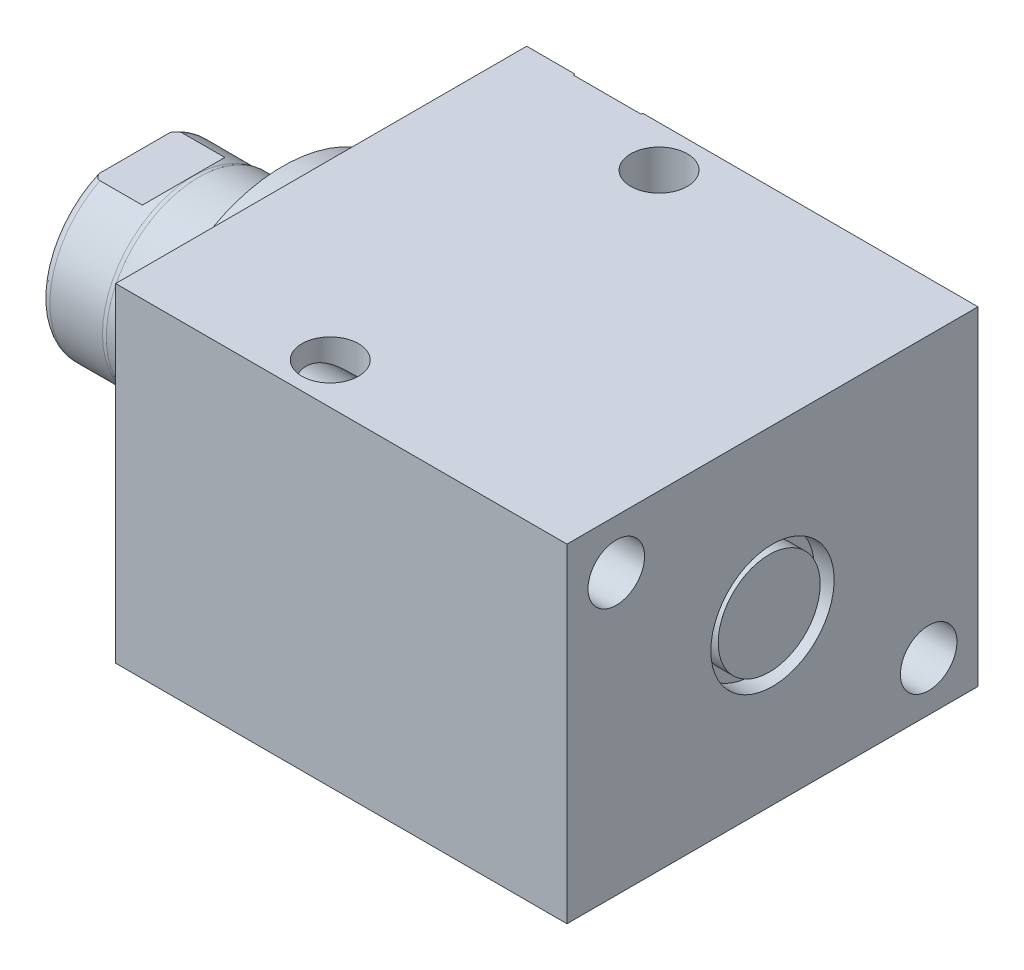
from build123d import *

# Parameters (mm, degrees)
SKETCH1_W          = 63.5
SKETCH1_H          = 50.8
EXTRUDE1_DEPTH     = 69.723
SKETCH5_R          = 22.225
EXTRUDE2_DEPTH     = 5.969
SKETCH6_W          = 14.2875
SKETCH6_H          = 22.86
CUT_EXTRUDE4_DEPTH = 30.48
SKETCH13_R         = 7.874
EXTRUDE3_DEPTH     = 2.54
HOLE1_D            = 8.7376
HOLE1_DEPTH        = 69.723
HOLE2_D            = 8.7376
HOLE2_DEPTH        = 50.8
SKETCH18_R         = 7.874
EXTRUDE4_DEPTH     = 2.54


with BuildPart() as part:
    # Sketch1 → Extrude1 (new body)
    with BuildSketch(Plane(origin=(0, 0, 0), x_dir=(0, 0, -1), z_dir=(1, 0, 0))):
        Rectangle(SKETCH1_W, SKETCH1_H)
    extrude(amount=EXTRUDE1_DEPTH)

    # S2D0002 → Cut-Revolve1 (revolve, cut)
    with BuildSketch(Plane(origin=(0, 17.4498, 0), x_dir=(-1, 0, 0), z_dir=(0, 1, 0)), mode=Mode.PRIVATE) as cut_revolve1_sk:
        Polygon((-18.8849, -31.496), (-22.225, -31.496), (-22.225, -31.75), (-12.7, -31.75), (-12.7, -17.526), (-17.6784, -17.526), (-17.6784, -28.279393135), (-18.342306865, -28.9433), align=None)
    revolve(cut_revolve1_sk.sketch.rotate(Axis((12.7, 17.4498, -19.13842003), (0, 0, 1)), 180), axis=Axis((12.7, 17.4498, -19.13842003), (0, 0, 1)), mode=Mode.SUBTRACT)  # turned: the seam where the file's is

    # Sketch3 → Cut-Revolve2 (revolve, cut)
    with BuildSketch(Plane(origin=(41.148, 0, -25.146), x_dir=(1, 0, 0), z_dir=(0, 1, 0))):
        Polygon((18.8849, 6.35), (22.225, 6.35), (22.225, 6.604), (12.7, 6.604), (12.7, -7.62), (17.6784, -7.62), (17.6784, 3.133393135), (18.342306865, 3.7973), align=None)
    revolve(axis=Axis((53.848, 0, -3.189624441), (0, 0, -1)), mode=Mode.SUBTRACT)

    # Sketch4 → Cut-Revolve3 (revolve, cut)
    with BuildSketch(Plane(origin=(53.975, 0, 0), x_dir=(0, -1, 0), z_dir=(0, 0, 1)), mode=Mode.PRIVATE) as cut_revolve3_sk:
        Polygon((6.1849, 12.7), (9.525, 12.7), (9.525, 15.748), (0, 15.748), (0, 1.3462), (4.9784, 1.3462), (4.9784, 9.483393135), (5.642306865, 10.1473), align=None)
    revolve(cut_revolve3_sk.sketch.rotate(Axis((38.879609832, 0, 0), (1, 0, 0)), 270), axis=Axis((38.879609832, 0, 0), (1, 0, 0)), mode=Mode.SUBTRACT)  # turned: the seam where the file's is

    # Sketch5 → Extrude2 (add)
    with BuildSketch(Plane.ZY):
        Circle(SKETCH5_R)
    extrude(amount=EXTRUDE2_DEPTH)

    # Sketch6 → Revolve1 (revolve)
    with BuildSketch(Plane(origin=(0, 0, 0), x_dir=(0, 0, 1), z_dir=(0, -1, 0)), mode=Mode.PRIVATE) as revolve1_sk:
        with Locations((-7.14375, 17.399)):
            Rectangle(SKETCH6_W, SKETCH6_H)
    revolve(revolve1_sk.sketch.rotate(Axis((5.754582971, 0, 0), (-1, 0, 0)), 180), axis=Axis((5.754582971, 0, 0), (-1, 0, 0)))  # turned: the seam where the file's is

    # S2D0001 → Cut-Revolve4 (revolve, cut)
    with BuildSketch(Plane(origin=(-18.511260017, 3.2639, 0), x_dir=(0, 1, 0), z_dir=(0, 0, 1)), mode=Mode.PRIVATE) as cut_revolve4_sk:
        Polygon((2.286, 8.250017728), (2.286, -6.522460017), (-3.2639, -6.522460017), (-3.2639, 10.317739983), (3.4798, 10.317739983), align=None)
    revolve(cut_revolve4_sk.sketch.rotate(Axis((0, 0, 0), (-1, 0, 0)), 270), axis=Axis((0, 0, 0), (-1, 0, 0)), mode=Mode.SUBTRACT)  # turned: the seam where the file's is

    # Sketch8 → Cut-Revolve5 (revolve, cut)
    with BuildSketch(Plane(origin=(0, 0, 0), x_dir=(0, 0, -1), z_dir=(0, 1, 0)), mode=Mode.PRIVATE) as cut_revolve5_sk:
        with BuildLine():
            Line((-14.2875, 18.923), (-14.097, 19.685))
            Line((-14.097, 19.685), (-14.097, 27.813))
            ThreePointArc((-14.097, 27.813), (-13.996678675, 28.356796865), (-13.708922533, 28.829))
            Line((-13.708922533, 28.829), (-14.2875, 28.829))
            Line((-14.2875, 28.829), (-14.2875, 18.923))
        make_face()
    revolve(cut_revolve5_sk.sketch.rotate(Axis((-12.65936, 0, 0), (-1, 0, 0)), 180), axis=Axis((-12.65936, 0, 0), (-1, 0, 0)), mode=Mode.SUBTRACT)  # turned: the seam where the file's is

    # Sketch12 → Cut-Extrude4 (cut, symmetric)
    with BuildSketch(Plane(origin=(0, 0, 0), x_dir=(0, -1, 0), z_dir=(0, 0, -1))):
        Polygon((12.573, 28.829), (12.573, 21.2598), (14.097, 19.7358), (14.097, 28.829), align=None)
        Polygon((-12.573, 28.829), (-12.573, 21.2598), (-14.097, 19.7358), (-14.097, 28.829), align=None)
    extrude(amount=CUT_EXTRUDE4_DEPTH, both=True, mode=Mode.SUBTRACT)

    # Sketch13 → Extrude3 (add)
    with BuildSketch(Plane(origin=(0, 0, -31.496), x_dir=(-1, 0, 0), z_dir=(0, 0, -1))):
        with Locations(Location((-53.848, 0, 0), (0, 0, 180))):  # turned: the seam where the file's is
            Circle(SKETCH13_R)
    extrude(amount=EXTRUDE3_DEPTH)

    # Hole1
    with Locations(Plane.ZY):
        with Locations((-24.13, -17.78), (24.13, 17.78)):
            Hole(HOLE1_D / 2, depth=HOLE1_DEPTH)

    # Hole2
    with Locations(Plane(origin=(0, 25.4, 0), x_dir=(-1, 0, 0), z_dir=(0, 1, 0))):
        with Locations((-26.797, -25.4), (-26.797, 25.4)):
            Hole(HOLE2_D / 2, depth=HOLE2_DEPTH)

    # Sketch18 → Extrude4 (add)
    with BuildSketch(Plane(origin=(66.675, 0, 0), x_dir=(0, 0, -1), z_dir=(1, 0, 0))):
        with Locations(Location((0, 0, 0), (0, 0, 180))):  # turned: the seam where the file's is
            Circle(SKETCH18_R)
    extrude(amount=EXTRUDE4_DEPTH)


solid = part.part
